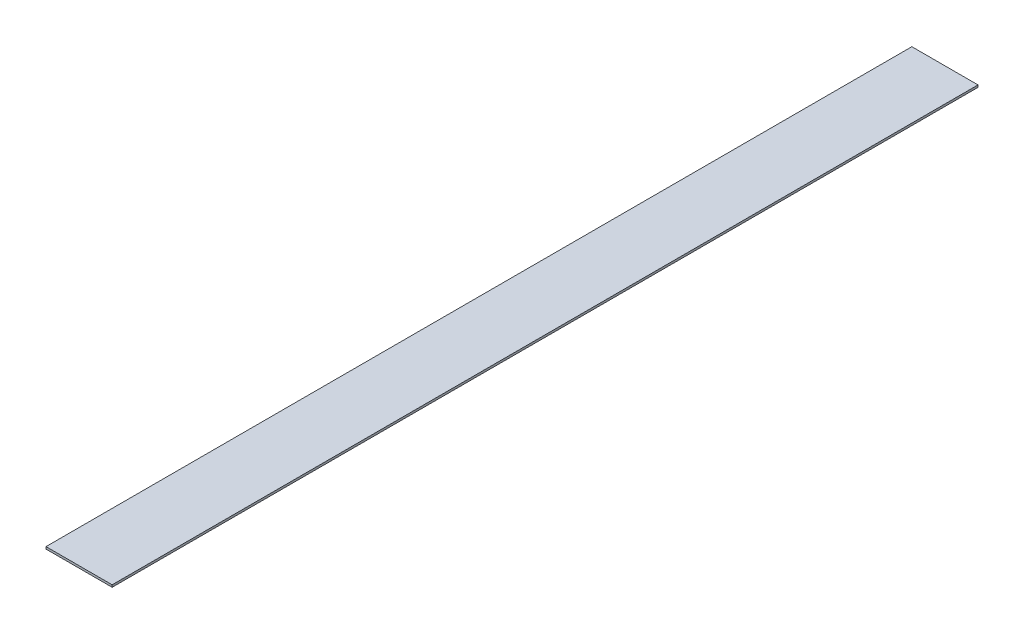
from build123d import *

# Parameters (mm, degrees)
SKETCH1_W              = 46.228
SKETCH1_H              = 1.524
DIFFUSER_PROFILE_DEPTH = 302.514


with BuildPart() as part:
    # Sketch1 → Diffuser Profile (new body, symmetric)
    with BuildSketch(Plane.XY):
        Rectangle(SKETCH1_W, SKETCH1_H)
    extrude(amount=DIFFUSER_PROFILE_DEPTH, both=True)


solid = part.part
